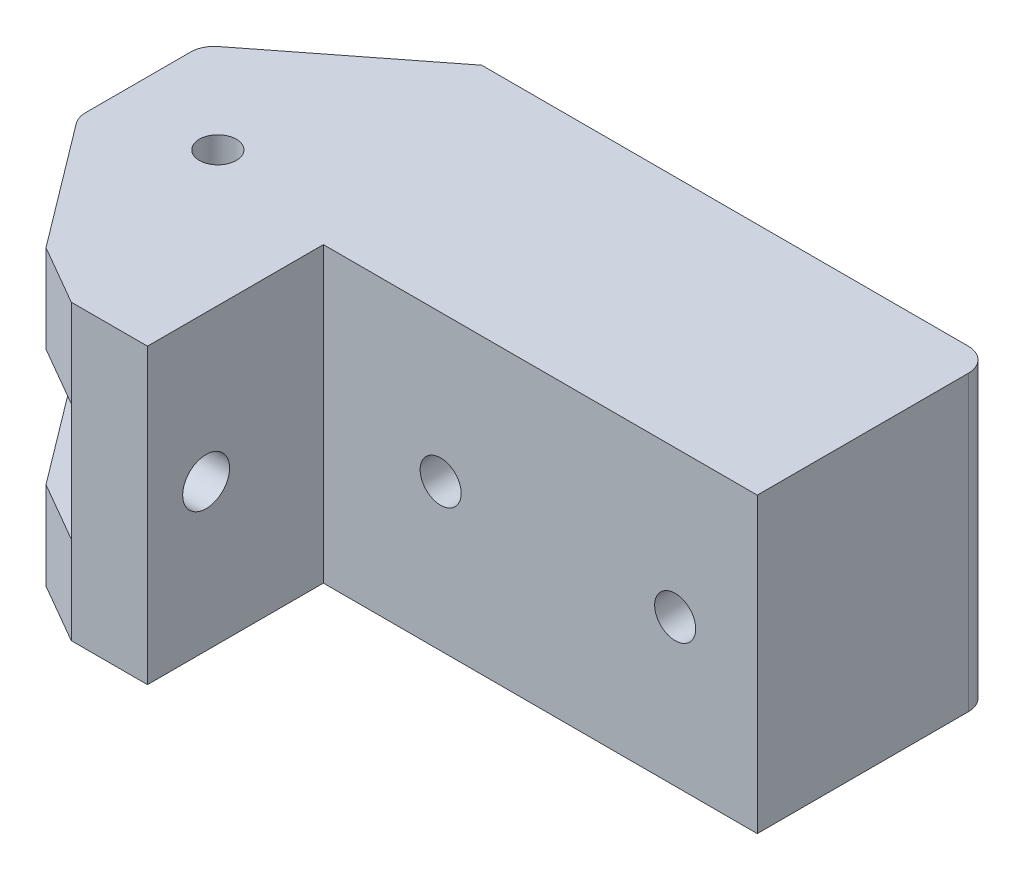
from build123d import *

# Parameters (mm, degrees)
SKETCH1_R               = 1.575
BOSS_EXTRUDE1_DEPTH     = 12.5
SKETCH2_W               = 13.385271969
SKETCH2_H               = 10
CUT_EXTRUDE1_DEPTH      = 36
SKETCH3_R               = 1.75
CUT_EXTRUDE2_DEPTH      = 25
SKETCH4_R               = 4
CUT_EXTRUDE3_DEPTH      = 4
FILLET1_R               = 2
SKETCH5_R               = 2
CUT_EXTRUDE4_DEPTH      = 10
SKETCH7_R               = 3.575
CUT_EXTRUDE5_DEPTH      = 3.5
SKETCH8_R               = 10
CUT_EXTRUDE6_DEPTH      = 5
CUT_EXTRUDE6_DEPTH_BACK = 5
CUT_EXTRUDE7_DEPTH      = 3


with BuildPart() as part:
    # Sketch1 → Boss-Extrude1 (new body, symmetric)
    with BuildSketch(Plane(origin=(0, 0, 0), x_dir=(1, 0, 0), z_dir=(0, 1, 0))):
        Polygon((0, 0), (-43.5, 0), (-56.885271969, -10.457720596), (-56.885271969, -21.057720596), (-48.596177418, -32.057720596), (-43.5, -35), (-37, -35), (-37, -20), (0, -20), align=None)
        with Locations((-48.5, -17.5)):
            Circle(SKETCH1_R, mode=Mode.SUBTRACT)
    extrude(amount=BOSS_EXTRUDE1_DEPTH, both=True)

    # Sketch2 → Cut-Extrude1 (cut, through all)
    with BuildSketch(Plane.XY.offset(35)):
        with Locations((-50.192635985, 0)):
            Rectangle(SKETCH2_W, SKETCH2_H)
    extrude(amount=-CUT_EXTRUDE1_DEPTH, mode=Mode.SUBTRACT)

    # Sketch3 → Cut-Extrude2 (cut)
    with BuildSketch(Plane.XY.offset(20)):
        with Locations((-27, 0)):
            Circle(SKETCH3_R)
        with Locations((-7, 0)):
            Circle(SKETCH3_R)
    extrude(amount=-CUT_EXTRUDE2_DEPTH, mode=Mode.SUBTRACT)

    # Sketch4 → Cut-Extrude3 (cut)
    with BuildSketch(Plane(origin=(0, 0, 0), x_dir=(-1, 0, 0), z_dir=(0, 0, -1))):
        with Locations((7, 0)):
            Circle(SKETCH4_R)
        with Locations((27, 0)):
            Circle(SKETCH4_R)
    extrude(amount=-CUT_EXTRUDE3_DEPTH, mode=Mode.SUBTRACT)

    # Fillet1
    fillet1_edges = [part.edges().sort_by_distance(p)[0] for p in [
        (-56.885271969, 8.75, 21.057720596),
        (-56.885271969, 8.75, 10.457720596),
        (0, 0, 0),
        (-56.885271969, -8.75, 21.057720596),
        (-56.885271969, -8.75, 10.457720596),
    ]]
    fillet(fillet1_edges, radius=FILLET1_R)

    # Sketch5 → Cut-Extrude4 (cut)
    with BuildSketch(Plane.ZY.offset(43.5)):
        with Locations((30, 0)):
            Circle(SKETCH5_R)
    extrude(amount=-CUT_EXTRUDE4_DEPTH, mode=Mode.SUBTRACT)

    # Sketch7 → Cut-Extrude5 (cut)
    with BuildSketch(Plane.ZY.offset(43.5)):
        with Locations((30, 0)):
            Circle(SKETCH7_R)
    extrude(amount=-CUT_EXTRUDE5_DEPTH, mode=Mode.SUBTRACT)

    # Sketch8 → Cut-Extrude6 (cut, two sides)
    with BuildSketch(Plane(origin=(0, 0, 0), x_dir=(1, 0, 0), z_dir=(0, 1, 0))) as cut_extrude6_sk:
        with Locations((-48.5, -17.5)):
            Circle(SKETCH8_R)
    extrude(amount=CUT_EXTRUDE6_DEPTH, mode=Mode.SUBTRACT)
    extrude(cut_extrude6_sk.sketch, amount=-CUT_EXTRUDE6_DEPTH_BACK, mode=Mode.SUBTRACT)

    # Sketch9 → Cut-Extrude7 (cut)
    with BuildSketch(Plane.XZ.offset(12.5)):
        Polygon((-46.800589834, 14.481390206), (-45.036102151, 17.462427479), (-46.735512318, 20.481037272), (-50.199410166, 20.518609794), (-51.963897849, 17.537572521), (-50.264487682, 14.518962728), align=None)
    extrude(amount=-CUT_EXTRUDE7_DEPTH, mode=Mode.SUBTRACT)


solid = part.part
